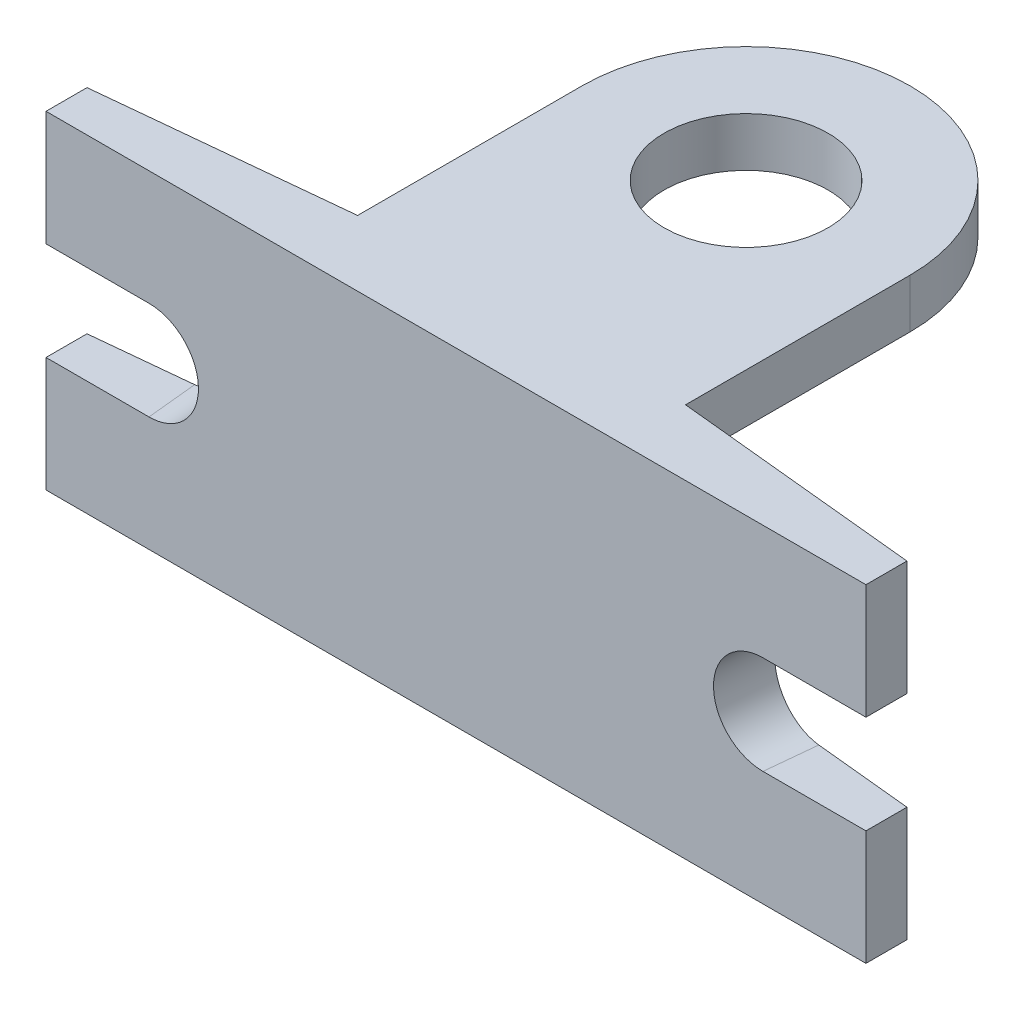
from build123d import *

# Parameters (mm, degrees)
BOSS_EXTRUDE1_DEPTH = 200
CUT_EXTRUDE1_DEPTH  = 30
CUT_EXTRUDE2_DEPTH  = 75.627789266
CUT_EXTRUDE3_DEPTH  = 75.627789266
SKETCH5_R           = 50
BOSS_EXTRUDE2_DEPTH = 30


with BuildPart() as part:
    # Sketch1 → Boss-Extrude1 (new body)
    with BuildSketch(Plane(origin=(0, 0, 0), x_dir=(1, 0, 0), z_dir=(0, 1, 0))):
        Polygon((-250, 0), (250, 0), (250, 25), (100, 40), (100, 50), (-100, 50), (-100, 40), (-250, 25), align=None)
    extrude(amount=BOSS_EXTRUDE1_DEPTH)

    # Sketch2 → Cut-Extrude1 (cut)
    with BuildSketch(Plane(origin=(0, 0, -50), x_dir=(-1, 0, 0), z_dir=(0, 0, -1))):
        with BuildLine():
            Line((-40, 0), (40, 0))
            Line((40, 0), (40, 90.399951474))
            ThreePointArc((40, 90.399951474), (0, 130.399951474), (-40, 90.399951474))
            Line((-40, 90.399951474), (-40, 0))
        make_face()
    extrude(amount=-CUT_EXTRUDE1_DEPTH, mode=Mode.SUBTRACT)

    # Sketch3 → Cut-Extrude2 (cut, through all)
    with BuildSketch(Plane(origin=(-4.95049505, 0, -49.504950495), x_dir=(-0.99503719, 0, 0.099503719), z_dir=(-0.099503719, 0, -0.99503719))):
        with BuildLine():
            Line((186.271704577, 130), (296.385375979, 130))
            Line((296.385375979, 130), (296.385375979, 70))
            Line((296.385375979, 70), (186.271704577, 70))
            ThreePointArc((186.271704577, 70), (156.271704577, 100), (186.271704577, 130))
        make_face()
    extrude(amount=-CUT_EXTRUDE2_DEPTH, mode=Mode.SUBTRACT)

    # Sketch4 → Cut-Extrude3 (cut, through all)
    with BuildSketch(Plane(origin=(4.95049505, 0, -49.504950495), x_dir=(-0.99503719, 0, -0.099503719), z_dir=(0.099503719, 0, -0.99503719))):
        with BuildLine():
            Line((-186.271704577, 130), (-315.600266526, 130))
            Line((-315.600266526, 130), (-315.600266526, 70))
            Line((-315.600266526, 70), (-186.271704577, 70))
            ThreePointArc((-186.271704577, 70), (-156.271704577, 100), (-186.271704577, 130))
        make_face()
    extrude(amount=-CUT_EXTRUDE3_DEPTH, mode=Mode.SUBTRACT)

    # Sketch5 → Boss-Extrude2 (add)
    with BuildSketch(Plane(origin=(0, 200, 0), x_dir=(1, 0, 0), z_dir=(0, 1, 0))):
        with BuildLine():
            Line((100, 50), (-100, 50))
            Line((-100, 50), (-100, 176.90746365))
            ThreePointArc((-100, 176.90746365), (0, 276.90746365), (100, 176.90746365))
            Line((100, 176.90746365), (100, 50))
        make_face()
        with Locations((0, 176.90746365)):
            Circle(SKETCH5_R, mode=Mode.SUBTRACT)
    extrude(amount=-BOSS_EXTRUDE2_DEPTH)


solid = part.part
